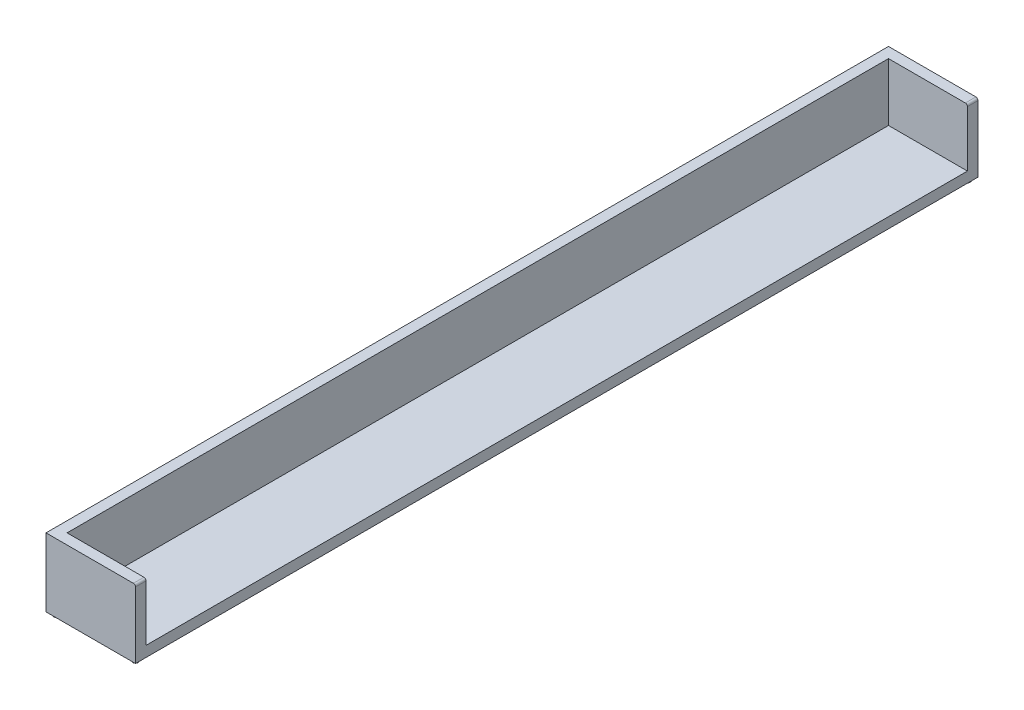
from build123d import *

# Parameters (mm, degrees)
BOSS_EXTRUDE1_DEPTH = 8000
SKETCH3_W           = 750
SKETCH3_H           = 7800
CUT_EXTRUDE1_DEPTH  = 550
SKETCH4_R           = 25
SKETCH4_R_2         = 40
BOSS_EXTRUDE2_DEPTH = 30


with BuildPart() as part:
    # Sketch2 → Boss-Extrude1 (new body)
    with BuildSketch(Plane.XY):
        with BuildLine():
            Line((-425, 325), (405, 325))
            ThreePointArc((405, 325), (419.142135624, 319.142135624), (425, 305))
            Line((425, 305), (425, -325))
            Line((425, -325), (-425, -325))
            Line((-425, -325), (-425, 325))
        make_face()
    extrude(amount=BOSS_EXTRUDE1_DEPTH)

    # Sketch3 → Cut-Extrude1 (cut)
    with BuildSketch(Plane(origin=(0, 325, 0), x_dir=(1, 0, 0), z_dir=(0, 1, 0))):
        with Locations((50, -4000)):
            Rectangle(SKETCH3_W, SKETCH3_H)
    extrude(amount=-CUT_EXTRUDE1_DEPTH, mode=Mode.SUBTRACT)

    # Sketch4 → Boss-Extrude2 (add)
    with BuildSketch(Plane(origin=(0, -325, 0), x_dir=(-1, 0, 0), z_dir=(0, -1, 0))):
        with Locations((375, -7950)):
            Circle(SKETCH4_R)
        with Locations((-375, -7950)):
            Circle(SKETCH4_R)
        with Locations((375, -50)):
            Circle(SKETCH4_R)
        with Locations((-375, -50)):
            Circle(SKETCH4_R)
        with Locations((0, -4000)):
            Circle(SKETCH4_R_2)
    extrude(amount=BOSS_EXTRUDE2_DEPTH)


solid = part.part
